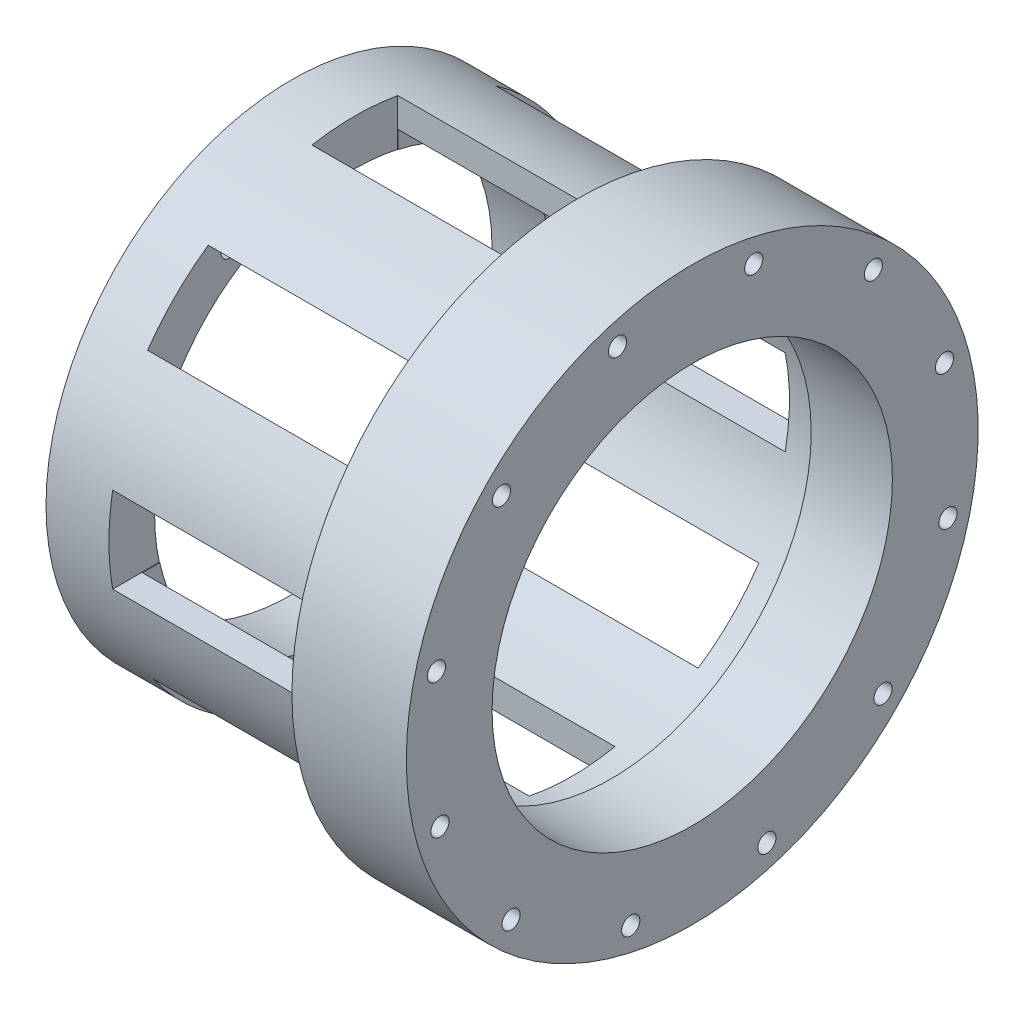
from build123d import *

# Parameters (mm, degrees)
UPPER_BOLT_HOLES_REACH  = 128.363
SKETCH4_R               = 2.0193
SKETCH6_R               = 2.0193
LOWER_BOLT_HOLES_DEPTH  = 12.7
SKETCH7_W               = 56.79526179
SKETCH7_H               = 3.81
SKETCH8_W               = 48.26
SKETCH8_H               = 19.05
SIDEWALL_CUTOUT_1_DEPTH = 76.2
SKETCH10_W              = 48.26
SKETCH10_H              = 19.05
SIDEWALL_CUTOUT_2_DEPTH = 76.2
SKETCH11_W              = 50.8
SKETCH11_H              = 19.05
SIDEWALL_CUTOUT_3_DEPTH = 76.2
SKETCH13_W              = 48.26
SKETCH13_H              = 19.05
SIDEWALL_CUTOUT_4_DEPTH = 76.2


with BuildPart() as part:
    # Sketch1 → Revolve1 (revolve)
    with BuildSketch(Plane.XY):
        Polygon((-88.9, 54.61), (-88.9, 44.45), (0, 44.45), (0, 63.5), (-25.4, 63.5), (-25.4, 54.61), align=None)
    revolve(axis=Axis((-87.283636364, 0, 0), (1, 0, 0)))

    # Sketch4 → Upper Bolt Holes (cut, up to next)
    with BuildSketch(Plane(origin=(0, 0, 0), x_dir=(0, 0, -1), z_dir=(1, 0, 0)), mode=Mode.PRIVATE) as upper_bolt_holes_sk1:
        with Locations((56.020377392, 16.571472984)):
            Circle(SKETCH4_R)
    upper_bolt_holes_tool1 = extrude(upper_bolt_holes_sk1.sketch, amount=-UPPER_BOLT_HOLES_REACH, mode=Mode.PRIVATE) & part.part
    # Sketch4 → Upper Bolt Holes (cut, up to next)
    with BuildSketch(Plane(origin=(0, 0, 0), x_dir=(0, 0, -1), z_dir=(1, 0, 0)), mode=Mode.PRIVATE) as upper_bolt_holes_sk2:
        with Locations((56.800806443, -13.658872113)):
            Circle(SKETCH4_R)
    upper_bolt_holes_tool2 = extrude(upper_bolt_holes_sk2.sketch, amount=-UPPER_BOLT_HOLES_REACH, mode=Mode.PRIVATE) & part.part
    # Sketch4 → Upper Bolt Holes (cut, up to next)
    with BuildSketch(Plane(origin=(0, 0, 0), x_dir=(0, 0, -1), z_dir=(1, 0, 0)), mode=Mode.PRIVATE) as upper_bolt_holes_sk3:
        with Locations((42.361505278, -40.229333459)):
            Circle(SKETCH4_R)
    upper_bolt_holes_tool3 = extrude(upper_bolt_holes_sk3.sketch, amount=-UPPER_BOLT_HOLES_REACH, mode=Mode.PRIVATE) & part.part
    # Sketch4 → Upper Bolt Holes (cut, up to next)
    with BuildSketch(Plane(origin=(0, 0, 0), x_dir=(0, 0, -1), z_dir=(1, 0, 0)), mode=Mode.PRIVATE) as upper_bolt_holes_sk4:
        with Locations((16.571472984, -56.020377392)):
            Circle(SKETCH4_R)
    upper_bolt_holes_tool4 = extrude(upper_bolt_holes_sk4.sketch, amount=-UPPER_BOLT_HOLES_REACH, mode=Mode.PRIVATE) & part.part
    # Sketch4 → Upper Bolt Holes (cut, up to next)
    with BuildSketch(Plane(origin=(0, 0, 0), x_dir=(0, 0, -1), z_dir=(1, 0, 0)), mode=Mode.PRIVATE) as upper_bolt_holes_sk5:
        with Locations((-13.658872113, -56.800806443)):
            Circle(SKETCH4_R)
    upper_bolt_holes_tool5 = extrude(upper_bolt_holes_sk5.sketch, amount=-UPPER_BOLT_HOLES_REACH, mode=Mode.PRIVATE) & part.part
    # Sketch4 → Upper Bolt Holes (cut, up to next)
    with BuildSketch(Plane(origin=(0, 0, 0), x_dir=(0, 0, -1), z_dir=(1, 0, 0)), mode=Mode.PRIVATE) as upper_bolt_holes_sk6:
        with Locations((-40.229333459, -42.361505278)):
            Circle(SKETCH4_R)
    upper_bolt_holes_tool6 = extrude(upper_bolt_holes_sk6.sketch, amount=-UPPER_BOLT_HOLES_REACH, mode=Mode.PRIVATE) & part.part
    # Sketch4 → Upper Bolt Holes (cut, up to next)
    with BuildSketch(Plane(origin=(0, 0, 0), x_dir=(0, 0, -1), z_dir=(1, 0, 0)), mode=Mode.PRIVATE) as upper_bolt_holes_sk7:
        with Locations((-56.020377392, -16.571472984)):
            Circle(SKETCH4_R)
    upper_bolt_holes_tool7 = extrude(upper_bolt_holes_sk7.sketch, amount=-UPPER_BOLT_HOLES_REACH, mode=Mode.PRIVATE) & part.part
    # Sketch4 → Upper Bolt Holes (cut, up to next)
    with BuildSketch(Plane(origin=(0, 0, 0), x_dir=(0, 0, -1), z_dir=(1, 0, 0)), mode=Mode.PRIVATE) as upper_bolt_holes_sk8:
        with Locations((-56.800806443, 13.658872113)):
            Circle(SKETCH4_R)
    upper_bolt_holes_tool8 = extrude(upper_bolt_holes_sk8.sketch, amount=-UPPER_BOLT_HOLES_REACH, mode=Mode.PRIVATE) & part.part
    # Sketch4 → Upper Bolt Holes (cut, up to next)
    with BuildSketch(Plane(origin=(0, 0, 0), x_dir=(0, 0, -1), z_dir=(1, 0, 0)), mode=Mode.PRIVATE) as upper_bolt_holes_sk9:
        with Locations((40.229333459, 42.361505278)):
            Circle(SKETCH4_R)
    upper_bolt_holes_tool9 = extrude(upper_bolt_holes_sk9.sketch, amount=-UPPER_BOLT_HOLES_REACH, mode=Mode.PRIVATE) & part.part
    # Sketch4 → Upper Bolt Holes (cut, up to next)
    with BuildSketch(Plane(origin=(0, 0, 0), x_dir=(0, 0, -1), z_dir=(1, 0, 0)), mode=Mode.PRIVATE) as upper_bolt_holes_sk10:
        with Locations((13.658872113, 56.800806443)):
            Circle(SKETCH4_R)
    upper_bolt_holes_tool10 = extrude(upper_bolt_holes_sk10.sketch, amount=-UPPER_BOLT_HOLES_REACH, mode=Mode.PRIVATE) & part.part
    # Sketch4 → Upper Bolt Holes (cut, up to next)
    with BuildSketch(Plane(origin=(0, 0, 0), x_dir=(0, 0, -1), z_dir=(1, 0, 0)), mode=Mode.PRIVATE) as upper_bolt_holes_sk11:
        with Locations((-16.571472984, 56.020377392)):
            Circle(SKETCH4_R)
    upper_bolt_holes_tool11 = extrude(upper_bolt_holes_sk11.sketch, amount=-UPPER_BOLT_HOLES_REACH, mode=Mode.PRIVATE) & part.part
    # Sketch4 → Upper Bolt Holes (cut, up to next)
    with BuildSketch(Plane(origin=(0, 0, 0), x_dir=(0, 0, -1), z_dir=(1, 0, 0)), mode=Mode.PRIVATE) as upper_bolt_holes_sk12:
        with Locations((-42.361505278, 40.229333459)):
            Circle(SKETCH4_R)
    upper_bolt_holes_tool12 = extrude(upper_bolt_holes_sk12.sketch, amount=-UPPER_BOLT_HOLES_REACH, mode=Mode.PRIVATE) & part.part
    add(upper_bolt_holes_tool1.solids().sort_by_distance((0, 16.571473, -56.020377))[0], mode=Mode.SUBTRACT)
    add(upper_bolt_holes_tool2.solids().sort_by_distance((0, -13.658872, -56.800806))[0], mode=Mode.SUBTRACT)
    add(upper_bolt_holes_tool3.solids().sort_by_distance((0, -40.229333, -42.361505))[0], mode=Mode.SUBTRACT)
    add(upper_bolt_holes_tool4.solids().sort_by_distance((0, -56.020377, -16.571473))[0], mode=Mode.SUBTRACT)
    add(upper_bolt_holes_tool5.solids().sort_by_distance((0, -56.800806, 13.658872))[0], mode=Mode.SUBTRACT)
    add(upper_bolt_holes_tool6.solids().sort_by_distance((0, -42.361505, 40.229333))[0], mode=Mode.SUBTRACT)
    add(upper_bolt_holes_tool7.solids().sort_by_distance((0, -16.571473, 56.020377))[0], mode=Mode.SUBTRACT)
    add(upper_bolt_holes_tool8.solids().sort_by_distance((0, 13.658872, 56.800806))[0], mode=Mode.SUBTRACT)
    add(upper_bolt_holes_tool9.solids().sort_by_distance((0, 42.361505, -40.229333))[0], mode=Mode.SUBTRACT)
    add(upper_bolt_holes_tool10.solids().sort_by_distance((0, 56.800806, -13.658872))[0], mode=Mode.SUBTRACT)
    add(upper_bolt_holes_tool11.solids().sort_by_distance((0, 56.020377, 16.571473))[0], mode=Mode.SUBTRACT)
    add(upper_bolt_holes_tool12.solids().sort_by_distance((0, 40.229333, 42.361505))[0], mode=Mode.SUBTRACT)

    # Sketch6 → Lower Bolt Holes (cut)
    with BuildSketch(Plane.ZY.offset(88.9)):
        with Locations((-10.905164891, 48.314576255)):
            Circle(SKETCH6_R)
        with Locations((26.452448456, 41.874680544)):
            Circle(SKETCH6_R)
        with Locations((48.314576255, 10.905164891)):
            Circle(SKETCH6_R)
        with Locations((41.874680544, -26.452448456)):
            Circle(SKETCH6_R)
        with Locations((10.905164891, -48.314576255)):
            Circle(SKETCH6_R)
        with Locations((-26.452448456, -41.874680544)):
            Circle(SKETCH6_R)
        with Locations((-48.314576255, -10.905164891)):
            Circle(SKETCH6_R)
        with Locations((-41.874680544, 26.452448456)):
            Circle(SKETCH6_R)
    extrude(amount=-LOWER_BOLT_HOLES_DEPTH, mode=Mode.SUBTRACT)

    # Sketch7 → 0.15in Depth Air Gap (revolve, cut)
    with BuildSketch(Plane.XY):
        with Locations((-46.425488876, 46.355)):
            Rectangle(SKETCH7_W, SKETCH7_H)
    revolve(axis=Axis((-102.668560336, 0, 0), (1, 0, 0)), mode=Mode.SUBTRACT)

    # Sketch8 → SideWall Cutout 1 (cut, symmetric)
    with BuildSketch(Plane(origin=(0, 0, 0), x_dir=(1, 0, 0), z_dir=(0, 1, 0))):
        with Locations((-50.8, 0)):
            Rectangle(SKETCH8_W, SKETCH8_H)
    extrude(amount=SIDEWALL_CUTOUT_1_DEPTH, both=True, mode=Mode.SUBTRACT)

    # Sketch10 → SideWall Cutout 2 (cut, symmetric)
    with BuildSketch(Plane.XY):
        with Locations((-50.8, 0)):
            Rectangle(SKETCH10_W, SKETCH10_H)
    extrude(amount=SIDEWALL_CUTOUT_2_DEPTH, both=True, mode=Mode.SUBTRACT)

    # Sketch11 → SideWall Cutout 3 (cut, symmetric)
    with BuildSketch(Plane(origin=(0, 0, 0), x_dir=(-1, 0, 0), z_dir=(0, 0.7071067811865488, 0.7071067811865464))):
        with Locations((50.8, 0)):
            Rectangle(SKETCH11_W, SKETCH11_H)
    extrude(amount=SIDEWALL_CUTOUT_3_DEPTH, both=True, mode=Mode.SUBTRACT)

    # Sketch13 → SideWall Cutout 4 (cut, symmetric)
    with BuildSketch(Plane(origin=(0, 0, 0), x_dir=(-1, 0, 0), z_dir=(0, -0.7071067811865488, 0.7071067811865464))):
        with Locations((50.8, 0)):
            Rectangle(SKETCH13_W, SKETCH13_H)
    extrude(amount=SIDEWALL_CUTOUT_4_DEPTH, both=True, mode=Mode.SUBTRACT)


solid = part.part
